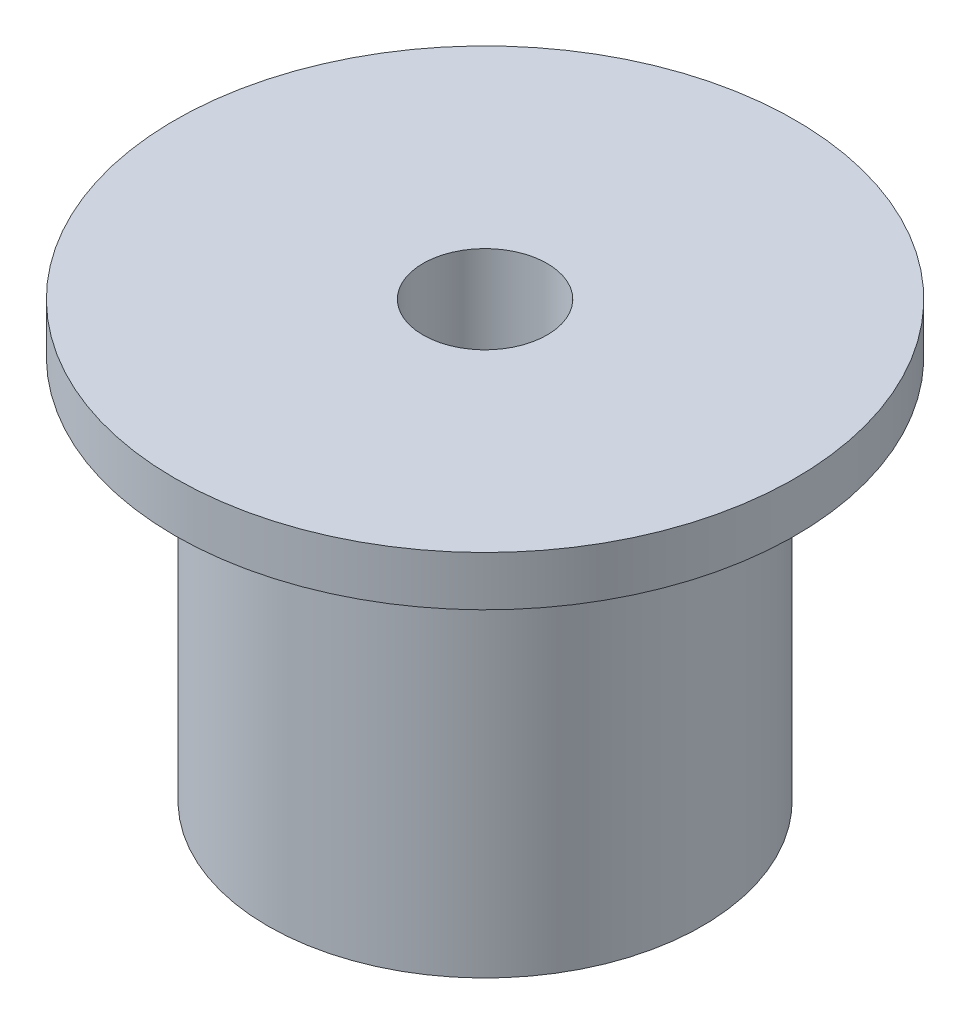
from build123d import *

# Parameters (mm, degrees)
SKETCH1_R                   = 11.1125
BOSS_EXTRUDE1_DEPTH         = 22.225
SKETCH2_R                   = 15.875
BOSS_EXTRUDE2_DEPTH         = 2.54
F_1_4_0_25_DIAMETER_HOLE1_D = 6.35


with BuildPart() as part:
    # Sketch1 → Boss-Extrude1 (new body)
    with BuildSketch(Plane(origin=(0, 0, 0), x_dir=(1, 0, 0), z_dir=(0, 1, 0))):
        Circle(SKETCH1_R)
    extrude(amount=BOSS_EXTRUDE1_DEPTH)

    # Sketch2 → Boss-Extrude2 (add)
    with BuildSketch(Plane(origin=(0, 22.225, 0), x_dir=(1, 0, 0), z_dir=(0, 1, 0))):
        Circle(SKETCH2_R)
    extrude(amount=-BOSS_EXTRUDE2_DEPTH)

    # 1/4 (0.25) Diameter Hole1 (through all)
    with Locations(Plane(origin=(0, 22.225, 0), x_dir=(1, 0, 0), z_dir=(0, 1, 0))):
        with Locations((0, 0)):
            Hole(F_1_4_0_25_DIAMETER_HOLE1_D / 2)


solid = part.part
